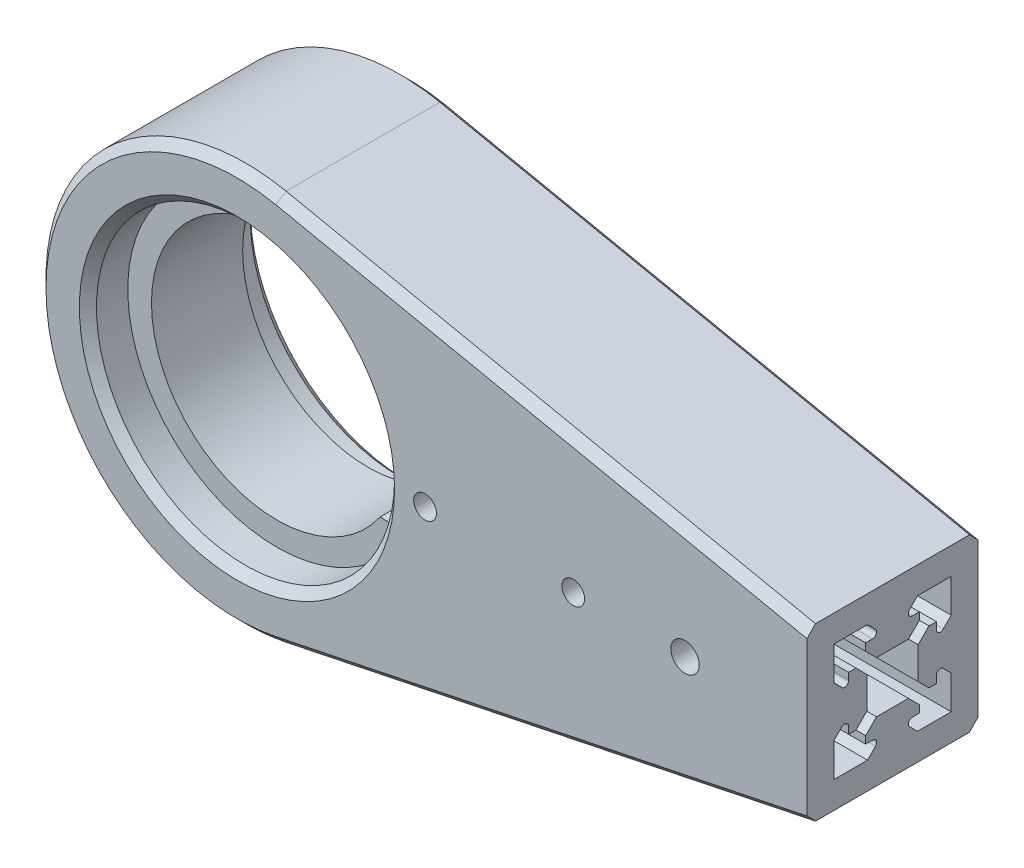
from build123d import *

# Parameters (mm, degrees)
SKETCH1_R           = 26.15
SKETCH1_R_2         = 2
SKETCH1_R_3         = 2.5
BOSS_EXTRUDE1_DEPTH = 30
BOSS_EXTRUDE2_START = -7
BOSS_EXTRUDE2_DEPTH = 16
CHAMFER1_SIZE       = 1.5
CUT_EXTRUDE1_DEPTH  = 90


with BuildPart() as part:
    # Sketch1 → Boss-Extrude1 (new body)
    with BuildSketch(Plane.XY):
        with BuildLine():
            Line((100, 15), (100, -15))
            Line((100, -15), (7.109450059, -34.270332941))
            ThreePointArc((7.109450059, -34.270332941), (-35, 0), (7.109450059, 34.270332941))
            Line((7.109450059, 34.270332941), (100, 15))
        make_face()
        Circle(SKETCH1_R, mode=Mode.SUBTRACT)
        with Locations((59, 0)):
            Circle(SKETCH1_R_2, mode=Mode.SUBTRACT)
        with Locations((78.6, 0)):
            Circle(SKETCH1_R_3, mode=Mode.SUBTRACT)
        with Locations((33, 0)):
            Circle(SKETCH1_R_2, mode=Mode.SUBTRACT)
    extrude(amount=BOSS_EXTRUDE1_DEPTH)

    # Sketch2 → Boss-Extrude2 (add)
    with BuildSketch(Plane.XY.offset(30).offset(BOSS_EXTRUDE2_START)):
        with BuildLine():
            Line((18.10386699, 12.5), (22.968946428, 12.5))
            ThreePointArc((22.968946428, 12.5), (-26.15, 0), (22.968946428, -12.5))
            Line((22.968946428, -12.5), (18.10386699, -12.5))
            ThreePointArc((18.10386699, -12.5), (-22, 0), (18.10386699, 12.5))
        make_face()
    extrude(amount=-BOSS_EXTRUDE2_DEPTH)

    # Chamfer1
    chamfer1_edges = [part.edges().sort_by_distance(p)[0] for p in [
        (-26.15, 0, 0),
        (-26.15, 0, 30),
        (53.554725029, -24.63516647, 30),
        (53.554725029, 24.63516647, 30),
        (53.554725029, -24.63516647, 0),
        (-35, 0, 0),
        (53.554725029, 24.63516647, 0),
        (-35, 0, 30),
    ]]
    chamfer(chamfer1_edges, length=CHAMFER1_SIZE)

    # Sketch3 → Cut-Extrude1 (cut)
    with BuildSketch(Plane(origin=(100, 0, 0), x_dir=(0, 0, -1), z_dir=(1, 0, 0))):
        with BuildLine():
            Line((-12.197056275, 4.5), (-17.802943725, 4.5))
            Line((-17.802943725, 4.5), (-19.710050506, 6.407106781))
            Line((-19.710050506, 6.407106781), (-19.710050506, 7.7))
            Line((-19.710050506, 7.7), (-18.482842712, 7.7))
            ThreePointArc((-18.482842712, 7.7), (-17.83612704, 8.132121597), (-17.987867966, 8.894974747))
            Line((-17.987867966, 8.894974747), (-19.387867966, 10.294974747))
            Line((-19.387867966, 10.294974747), (-25.294974747, 10.294974747))
            Line((-25.294974747, 10.294974747), (-25.294974747, 4.387867966))
            Line((-25.294974747, 4.387867966), (-23.894974747, 2.987867966))
            ThreePointArc((-23.894974747, 2.987867966), (-23.132121597, 2.83612704), (-22.7, 3.482842712))
            Line((-22.7, 3.482842712), (-22.7, 4.710050506))
            Line((-22.7, 4.710050506), (-21.407106781, 4.710050506))
            Line((-21.407106781, 4.710050506), (-19.5, 2.802943725))
            Line((-19.5, 2.802943725), (-19.5, -2.802943725))
            Line((-19.5, -2.802943725), (-21.407106781, -4.710050506))
            Line((-21.407106781, -4.710050506), (-22.7, -4.710050506))
            Line((-22.7, -4.710050506), (-22.7, -3.482842712))
            ThreePointArc((-22.7, -3.482842712), (-23.132121597, -2.83612704), (-23.894974747, -2.987867966))
            Line((-23.894974747, -2.987867966), (-25.294974747, -4.387867966))
            Line((-25.294974747, -4.387867966), (-25.294974747, -10.294974747))
            Line((-25.294974747, -10.294974747), (-19.387867966, -10.294974747))
            Line((-19.387867966, -10.294974747), (-17.987867966, -8.894974747))
            ThreePointArc((-17.987867966, -8.894974747), (-17.83612704, -8.132121597), (-18.482842712, -7.7))
            Line((-18.482842712, -7.7), (-19.710050506, -7.7))
            Line((-19.710050506, -7.7), (-19.710050506, -6.407106781))
            Line((-19.710050506, -6.407106781), (-17.802943725, -4.5))
            Line((-17.802943725, -4.5), (-12.197056275, -4.5))
            Line((-12.197056275, -4.5), (-10.289949494, -6.407106781))
            Line((-10.289949494, -6.407106781), (-10.289949494, -7.7))
            Line((-10.289949494, -7.7), (-11.517157288, -7.7))
            ThreePointArc((-11.517157288, -7.7), (-12.16387296, -8.132121597), (-12.012132034, -8.894974747))
            Line((-12.012132034, -8.894974747), (-10.612132034, -10.294974747))
            Line((-10.612132034, -10.294974747), (-4.705025253, -10.294974747))
            Line((-4.705025253, -10.294974747), (-4.705025253, -4.387867966))
            Line((-4.705025253, -4.387867966), (-6.105025253, -2.987867966))
            ThreePointArc((-6.105025253, -2.987867966), (-6.867878403, -2.83612704), (-7.3, -3.482842712))
            Line((-7.3, -3.482842712), (-7.3, -4.710050506))
            Line((-7.3, -4.710050506), (-8.592893219, -4.710050506))
            Line((-8.592893219, -4.710050506), (-10.5, -2.802943725))
            Line((-10.5, -2.802943725), (-10.5, 2.802943725))
            Line((-10.5, 2.802943725), (-8.592893219, 4.710050506))
            Line((-8.592893219, 4.710050506), (-7.3, 4.710050506))
            Line((-7.3, 4.710050506), (-7.3, 3.482842712))
            ThreePointArc((-7.3, 3.482842712), (-6.867878403, 2.83612704), (-6.105025253, 2.987867966))
            Line((-6.105025253, 2.987867966), (-4.705025253, 4.387867966))
            Line((-4.705025253, 4.387867966), (-4.705025253, 10.294974747))
            Line((-4.705025253, 10.294974747), (-10.612132034, 10.294974747))
            Line((-10.612132034, 10.294974747), (-12.012132034, 8.894974747))
            ThreePointArc((-12.012132034, 8.894974747), (-12.16387296, 8.132121597), (-11.517157288, 7.7))
            Line((-11.517157288, 7.7), (-10.289949494, 7.7))
            Line((-10.289949494, 7.7), (-10.289949494, 6.407106781))
            Line((-10.289949494, 6.407106781), (-12.197056275, 4.5))
        make_face()
    extrude(amount=-CUT_EXTRUDE1_DEPTH, mode=Mode.SUBTRACT)


solid = part.part
